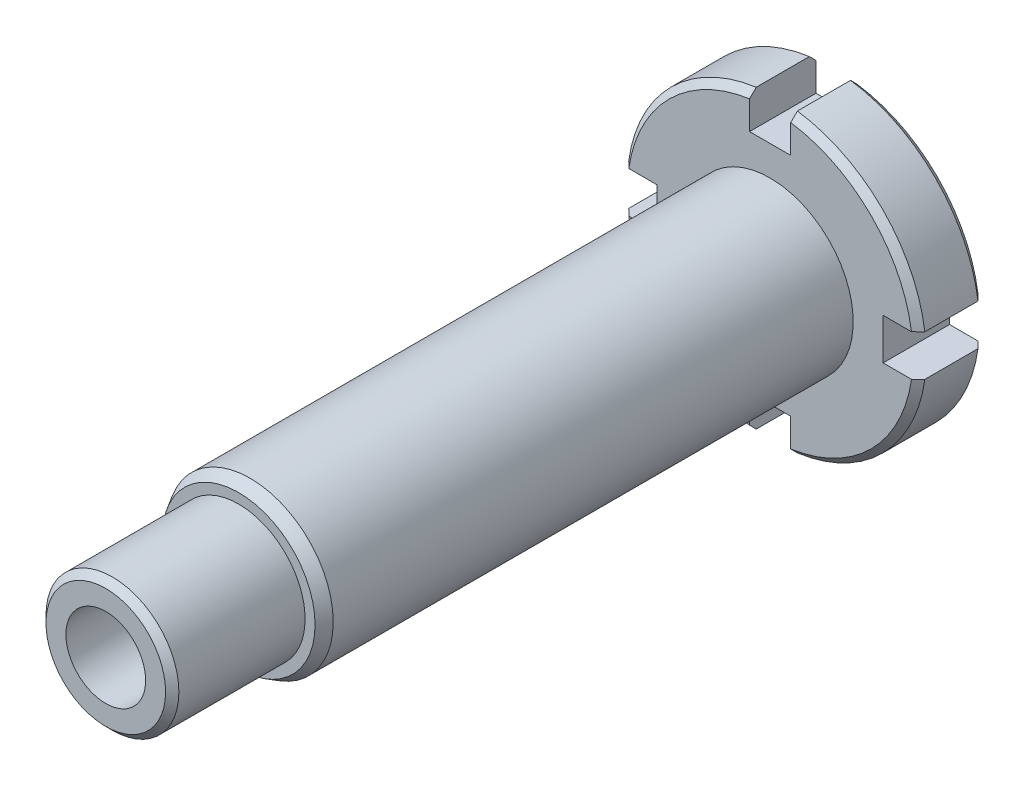
from build123d import *

# Parameters (mm, degrees)
CHANFREIN1_SIZE              = 1
ESQUISSE3_R                  = 6
ENL_V_MAT_EXTRU_2_DEPTH      = 111
ENL_V_MAT_EXTRU_1_DEPTH      = 111
R_P_TITION_CIRCULAIRE1_COUNT = 4
CHANFREIN2_SIZE              = 1
CHANFREIN2_SIZE2             = 1.732050808


with BuildPart() as part:
    # Esquisse1 → Révolution1 (revolve)
    with BuildSketch(Plane(origin=(0, 0, 0), x_dir=(0, 0, -1), z_dir=(1, 0, 0)), mode=Mode.PRIVATE) as r_volution1_sk:
        Polygon((-110, 0), (-110, 10), (-90, 10), (-90, 12.5), (-10, 12.5), (-10, 22.5), (0, 22.5), (0, 0), align=None)
    revolve(r_volution1_sk.sketch.rotate(Axis((0, 0, 0), (0, 0, 1)), 90), axis=Axis((0, 0, 0), (0, 0, 1)))  # turned: the seam where the file's is

    # Chanfrein1
    chanfrein1_edges = [part.edges().sort_by_distance(p)[0] for p in [
        (22.5, 0, 0),
        (22.5, 0, 10),
        (10, 0, 110),
    ]]
    chamfer(chanfrein1_edges, length=CHANFREIN1_SIZE)

    # Esquisse3 → Enlèv. mat.-Extru.2 (cut, through all)
    with BuildSketch(Plane(origin=(0, 0, 0), x_dir=(-1, 0, 0), z_dir=(0, 0, -1))):
        Circle(ESQUISSE3_R)
    extrude(amount=-ENL_V_MAT_EXTRU_2_DEPTH, mode=Mode.SUBTRACT)

    # Esquisse2 → Enlèv. mat.-Extru.1 (cut, through all)
    with BuildSketch(Plane(origin=(0, 0, 0), x_dir=(-1, 0, 0), z_dir=(0, 0, -1))):
        with BuildLine():
            Line((-3.1, 22.285421243), (-3.1, 17))
            Line((-3.1, 17), (3.1, 17))
            Line((3.1, 17), (3.1, 22.285421243))
            ThreePointArc((3.1, 22.285421243), (0, 22.5), (-3.1, 22.285421243))
        make_face()
    enl_v_mat_extru_1 = extrude(amount=-ENL_V_MAT_EXTRU_1_DEPTH, mode=Mode.SUBTRACT)

    # Répétition circulaire1: Enlèv. mat.-Extru.1 ×4 about axis
    r_p_tition_circulaire1_axis = Axis((0, 0, 0), (0, 0, 1))
    for i in range(1, R_P_TITION_CIRCULAIRE1_COUNT):
        add(enl_v_mat_extru_1.rotate(r_p_tition_circulaire1_axis, i * 360 / R_P_TITION_CIRCULAIRE1_COUNT), mode=Mode.SUBTRACT)

    # Chanfrein2
    chanfrein2_edges = [part.edges().sort_by_distance(p)[0] for p in [
        (12.5, 0, 90),
    ]]
    chanfrein2_side = [part.faces().sort_by_distance(p)[0] for p in [
        (10.353553391, 0, 90),
    ]]
    chamfer(chanfrein2_edges, length=CHANFREIN2_SIZE, length2=CHANFREIN2_SIZE2, reference=chanfrein2_side[0])


solid = part.part
